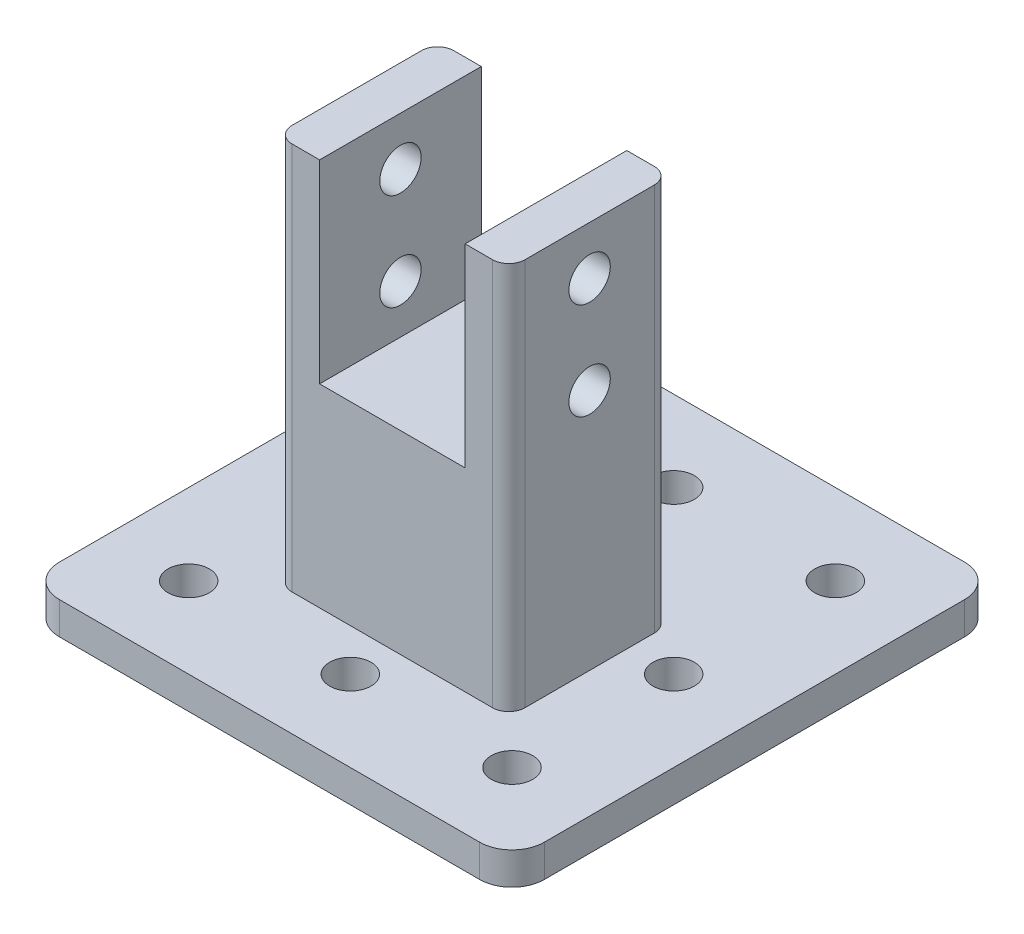
from build123d import *

# Parameters (mm, degrees)
EXTRUDE_2_DEPTH     = 5
SKETCH_2_R          = 3.2
CUT_EXTRUDE_1_DEPTH = 5
SKETCH_4_W          = 36
SKETCH_4_H          = 25
EXTRUDE_3_DEPTH     = 30
FILLET_1_R          = 2.5
EXTRUDE_4_DEPTH     = 30
SKETCH_6_R          = 3.2
CUT_EXTRUDE_2_DEPTH = 36


with BuildPart() as part:
    # 스케치1 → 보스-돌출2 (new body)
    with BuildSketch(Plane(origin=(0, 0, 0), x_dir=(1, 0, 0), z_dir=(0, 1, 0))):
        with BuildLine():
            Line((-32.5, 37.5), (32.5, 37.5))
            ThreePointArc((32.5, 37.5), (36.035533906, 36.035533906), (37.5, 32.5))
            Line((37.5, 32.5), (37.5, -32.5))
            ThreePointArc((37.5, -32.5), (36.035533906, -36.035533906), (32.5, -37.5))
            Line((32.5, -37.5), (-32.5, -37.5))
            ThreePointArc((-32.5, -37.5), (-36.035533906, -36.035533906), (-37.5, -32.5))
            Line((-37.5, -32.5), (-37.5, 32.5))
            ThreePointArc((-37.5, 32.5), (-36.035533906, 36.035533906), (-32.5, 37.5))
        make_face()
    extrude(amount=EXTRUDE_2_DEPTH)

    # 스케치2 → 컷-돌출1 (cut)
    with BuildSketch(Plane(origin=(0, 5, 0), x_dir=(1, 0, 0), z_dir=(0, 1, 0))):
        with Locations((0, 25)):
            Circle(SKETCH_2_R)
        with Locations((-25, 25)):
            Circle(SKETCH_2_R)
        with Locations((-25, 0)):
            Circle(SKETCH_2_R)
        with Locations((-25, -25)):
            Circle(SKETCH_2_R)
        with Locations((0, -25)):
            Circle(SKETCH_2_R)
        with Locations((25, -25)):
            Circle(SKETCH_2_R)
        with Locations((25, 0)):
            Circle(SKETCH_2_R)
        with Locations((25, 25)):
            Circle(SKETCH_2_R)
    extrude(amount=-CUT_EXTRUDE_1_DEPTH, mode=Mode.SUBTRACT)

    # 스케치4 → 보스-돌출3 (add)
    with BuildSketch(Plane(origin=(0, 35, 0), x_dir=(-1, 0, 0), z_dir=(0, -1, 0))):
        with Locations((0, -6)):
            Rectangle(SKETCH_4_W, SKETCH_4_H)
    extrude(amount=EXTRUDE_3_DEPTH)

    # 필렛1
    fillet_1_edges = [part.edges().sort_by_distance(p)[0] for p in [
        (-18, 20, -6.5),
        (-18, 20, 18.5),
        (18, 20, 18.5),
        (18, 20, -6.5),
    ]]
    fillet(fillet_1_edges, radius=FILLET_1_R)

    # 스케치5 → 보스-돌출4 (add)
    with BuildSketch(Plane(origin=(0, 65, 0), x_dir=(-1, 0, 0), z_dir=(0, -1, 0))):
        with BuildLine():
            Line((18, -16), (18, 4))
            ThreePointArc((18, 4), (17.267766953, 5.767766953), (15.5, 6.5))
            Line((15.5, 6.5), (11.25, 6.5))
            Line((11.25, 6.5), (11.25, -18.5))
            Line((11.25, -18.5), (15.5, -18.5))
            ThreePointArc((15.5, -18.5), (17.267766953, -17.767766953), (18, -16))
        make_face()
        with BuildLine():
            Line((-18, -16), (-18, 4))
            ThreePointArc((-18, 4), (-17.267766953, 5.767766953), (-15.5, 6.5))
            Line((-15.5, 6.5), (-11.25, 6.5))
            Line((-11.25, 6.5), (-11.25, -18.5))
            Line((-11.25, -18.5), (-15.5, -18.5))
            ThreePointArc((-15.5, -18.5), (-17.267766953, -17.767766953), (-18, -16))
        make_face()
    extrude(amount=EXTRUDE_4_DEPTH)

    # 스케치6 → 컷-돌출2 (cut)
    with BuildSketch(Plane(origin=(18, 0, 0), x_dir=(0, 0, -1), z_dir=(1, 0, 0))):
        with Locations((-6, 57.5)):
            Circle(SKETCH_6_R)
        with Locations((-6, 42.5)):
            Circle(SKETCH_6_R)
    extrude(amount=-CUT_EXTRUDE_2_DEPTH, mode=Mode.SUBTRACT)


solid = part.part
